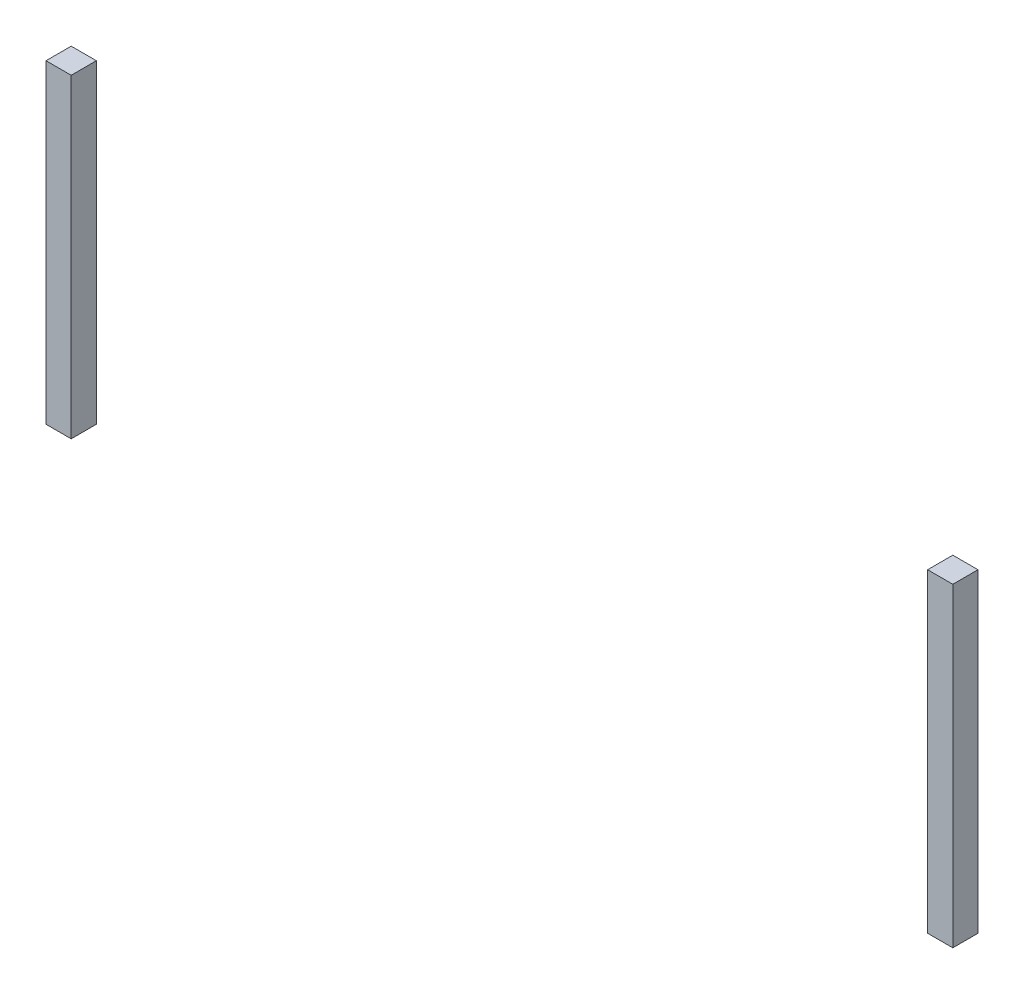
from build123d import *

# Parameters (mm, degrees)
SKETCH1_W             = 0.1
SKETCH1_H             = 0.1
BOSS_EXTRUDE1_DEPTH   = 1.25
BOSS_EXTRUDE1_2_DEPTH = 1.25


with BuildPart() as part:
    # Sketch1 → Boss-Extrude1 (new body)
    with BuildSketch(Plane(origin=(0, 0, 0), x_dir=(1, 0, 0), z_dir=(0, 1, 0))):
        with Locations((-1.75, 0.05)):
            Rectangle(SKETCH1_W, SKETCH1_H)
    extrude(amount=BOSS_EXTRUDE1_DEPTH)


with BuildPart() as body_2:
    # Sketch1 → Boss-Extrude1 2 (new body)
    with BuildSketch(Plane(origin=(0, 0, 0), x_dir=(1, 0, 0), z_dir=(0, 1, 0))):
        with Locations((1.75, 0.05)):
            Rectangle(SKETCH1_W, SKETCH1_H)
    extrude(amount=BOSS_EXTRUDE1_2_DEPTH)


solid = Compound([part.part, body_2.part])
